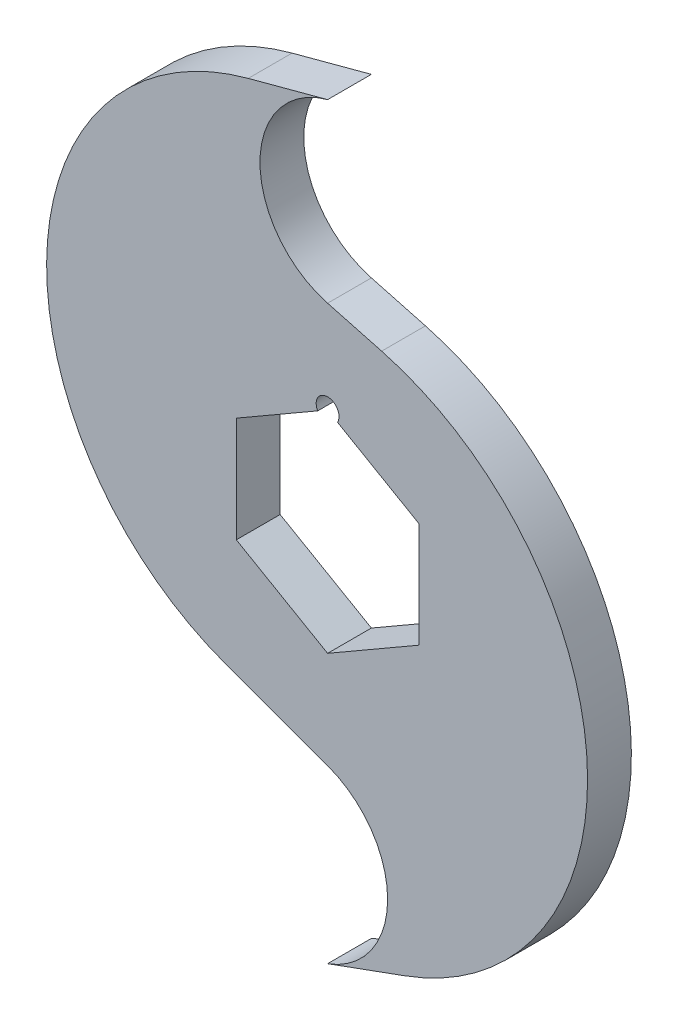
from build123d import *

# Parameters (mm, degrees)
BOSS_EXTRUDE1_DEPTH = 3.048


with BuildPart() as part:
    # Sketch1 → Boss-Extrude1 (new body, symmetric)
    with BuildSketch(Plane.XY):
        with BuildLine():
            ThreePointArc((0, 27.535484012), (-9.412998127, 39.802742006), (0, 52.07))
            Line((0, 52.07), (-11.040532194, 49.111698314))
            ThreePointArc((-11.040532194, 49.111698314), (-39.066320922, 14.192289272), (-14.190605813, -23.03684931))
            Line((-14.190605813, -23.03684931), (0, -28.201807432))
            ThreePointArc((0, -28.201807432), (8.35634418, -40.135903716), (0, -52.07))
            Line((0, -52.07), (10.740686656, -48.160709762))
            ThreePointArc((10.740686656, -48.160709762), (36.144496882, -10.141220984), (7.52373904, 25.519504212))
            Line((7.52373904, 25.519504212), (0, 27.535484012))
        make_face()
        with BuildLine():
            Line((-12.7, 7.332348419), (-1.374815329, 13.870946837))
            ThreePointArc((-1.374815329, 13.870946837), (-0.410875234, 16.198104087), (1.5875, 14.664696837))
            ThreePointArc((1.5875, 14.664696837), (1.533407249, 14.253821603), (1.374815329, 13.870946837))
            Line((1.374815329, 13.870946837), (12.7, 7.332348419))
            Line((12.7, 7.332348419), (12.7, -7.332348419))
            Line((12.7, -7.332348419), (0, -14.664696837))
            Line((0, -14.664696837), (-12.7, -7.332348419))
            Line((-12.7, -7.332348419), (-12.7, 7.332348419))
        make_face(mode=Mode.SUBTRACT)
    extrude(amount=BOSS_EXTRUDE1_DEPTH, both=True)


solid = part.part
